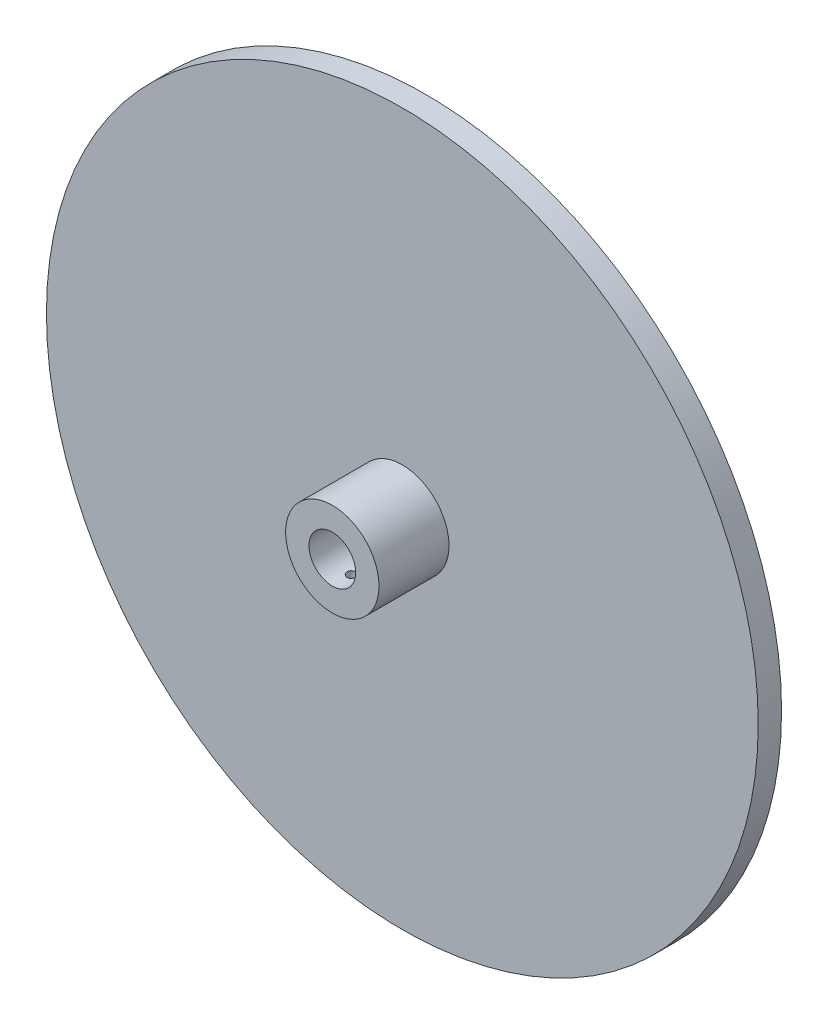
from build123d import *

# Parameters (mm, degrees)
SKETCH1_R           = 152.5
SKETCH1_R_2         = 10
BOSS_EXTRUDE1_DEPTH = 10
SKETCH2_R           = 20
SKETCH2_R_2         = 10
BOSS_EXTRUDE2_DEPTH = 30
SKETCH3_R           = 2
CUT_EXTRUDE1_DEPTH  = 60


with BuildPart() as part:
    # Sketch1 → Boss-Extrude1 (new body)
    with BuildSketch(Plane.XY):
        Circle(SKETCH1_R)
        Circle(SKETCH1_R_2, mode=Mode.SUBTRACT)
    extrude(amount=BOSS_EXTRUDE1_DEPTH)

    # Sketch2 → Boss-Extrude2 (add)
    with BuildSketch(Plane.XY.offset(10)):
        Circle(SKETCH2_R)
        Circle(SKETCH2_R_2, mode=Mode.SUBTRACT)
    extrude(amount=BOSS_EXTRUDE2_DEPTH)

    # Sketch3 → Cut-Extrude1 (cut)
    with BuildSketch(Plane(origin=(0, 0, 0), x_dir=(1, 0, 0), z_dir=(0, 1, 0))):
        with Locations(Location((0, -31.638618724, 0), (0, 0, 270))):  # turned: the seam where the file's is
            Circle(SKETCH3_R)
    extrude(amount=-CUT_EXTRUDE1_DEPTH, mode=Mode.SUBTRACT)


solid = part.part
